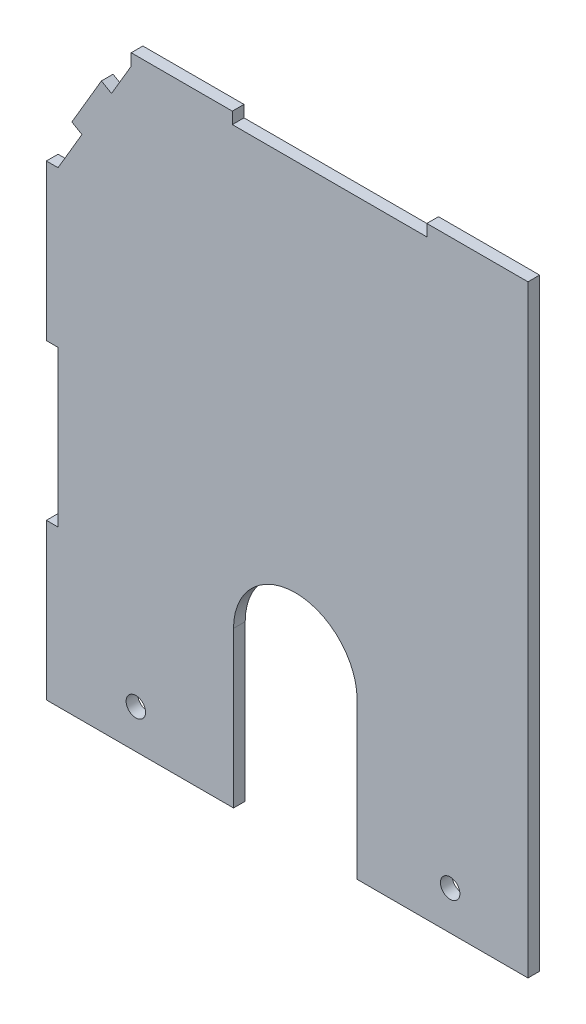
from build123d import *

# Parameters (mm, degrees)
SKETCH1_R           = 2.5
BOSS_EXTRUDE1_DEPTH = 3


with BuildPart() as part:
    # Sketch1 → Boss-Extrude1 (new body)
    with BuildSketch(Plane.XY):
        with BuildLine():
            Line((34.37, 75.95596391), (-15.63, 75.95596391))
            Line((-15.63, 75.95596391), (-15.63, 78.95596391))
            Line((-15.63, 78.95596391), (-41.63, 78.95596391))
            Line((-41.63, 78.95596391), (-41.63, 75.95596391))
            Line((-41.63, 75.95596391), (-46.697493122, 67.335029306))
            Line((-46.697493122, 67.335029306), (-49.283773504, 68.855277242))
            Line((-49.283773504, 68.855277242), (-56.885013187, 55.923875336))
            Line((-56.885013187, 55.923875336), (-54.298732806, 54.403627399))
            Line((-54.298732806, 54.403627399), (-60.44, 43.95596391))
            Line((-60.44, 43.95596391), (-63.44, 43.95596391))
            Line((-63.44, 43.95596391), (-63.44, 3.95596391))
            Line((-63.44, 3.95596391), (-60.44, 3.95596391))
            Line((-60.44, 3.95596391), (-60.44, -36.04403609))
            Line((-60.44, -36.04403609), (-63.44, -36.04403609))
            Line((-63.44, -36.04403609), (-63.44, -76.04403609))
            Line((-63.44, -76.04403609), (-60.44, -76.04403609))
            Line((-60.44, -76.04403609), (-15.324347337, -76.04403609))
            Line((-15.324347337, -76.04403609), (-15.324347337, -36.04403609))
            ThreePointArc((-15.324347337, -36.04403609), (0.56, -20.159688753), (16.444347337, -36.04403609))
            Line((16.444347337, -36.04403609), (16.444347337, -76.04403609))
            Line((16.444347337, -76.04403609), (60.37, -76.04403609))
            Line((60.37, -76.04403609), (60.37, 75.95596391))
            Line((60.37, 75.95596391), (60.37, 78.95596391))
            Line((60.37, 78.95596391), (34.37, 78.95596391))
            Line((34.37, 78.95596391), (34.37, 75.95596391))
        make_face()
        with Locations((-40.44, -66.04403609)):
            Circle(SKETCH1_R, mode=Mode.SUBTRACT)
        with Locations((40.37, -66.04403609)):
            Circle(SKETCH1_R, mode=Mode.SUBTRACT)
    extrude(amount=BOSS_EXTRUDE1_DEPTH)


solid = part.part
